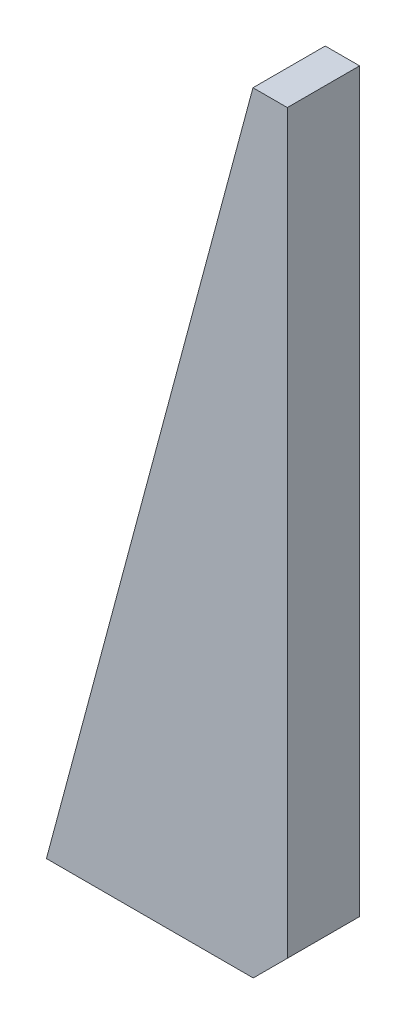
from build123d import *

# Parameters (mm, degrees)
BOSS_EXTRUDE1_DEPTH = 15


with BuildPart() as part:
    # Sketch1 → Boss-Extrude1 (new body)
    with BuildSketch(Plane.XY):
        Polygon((-50, 0), (-7.071067812, 0), (0, 7.071067812), (0, 160), (-7.128129211, 160), align=None)
    extrude(amount=-BOSS_EXTRUDE1_DEPTH)


solid = part.part
